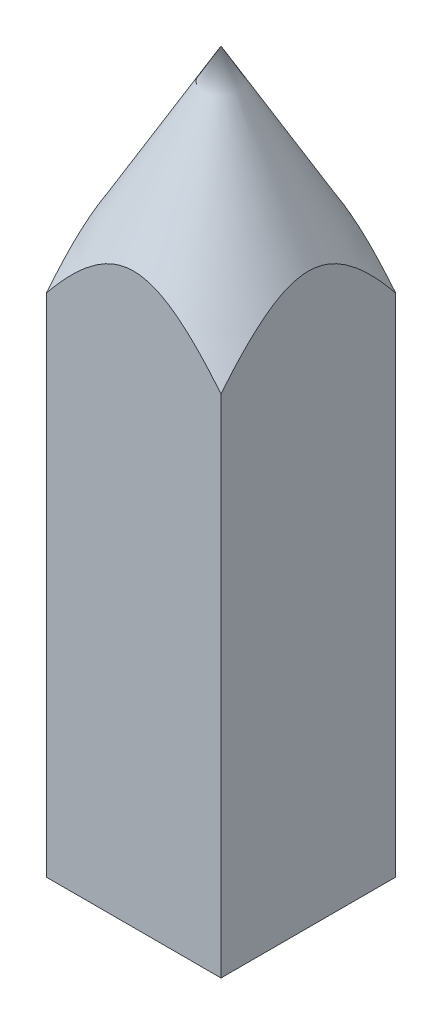
from build123d import *

# Parameters (mm, degrees)
SKETCH5_OUTSIDE_W   = 25.302
SKETCH5_OUTSIDE_H   = 25.302
SKETCH5_OUTSIDE_W_2 = 10
SKETCH5_OUTSIDE_H_2 = 10
EXTRUDE2_DEPTH      = 42.2052629


with BuildPart() as part:
    # Sketch4 → Revolve1 (revolve)
    with BuildSketch(Plane.XY, mode=Mode.PRIVATE) as revolve1_sk:
        Polygon((0, 0), (0, 41.2052629), (7.071067812, 28.957814186), (7.071067812, 0), align=None)
    revolve(revolve1_sk.sketch.rotate(Axis((0, 0, 0), (0, 1, 0)), 90), axis=Axis((0, 0, 0), (0, 1, 0)))  # turned: the seam where the file's is

    # Sketch5 outside → Extrude2 (cut, through all)
    with BuildSketch(Plane(origin=(0, 0, 0), x_dir=(1, 0, 0), z_dir=(0, 1, 0))):
        Rectangle(SKETCH5_OUTSIDE_W, SKETCH5_OUTSIDE_H)
        Rectangle(SKETCH5_OUTSIDE_W_2, SKETCH5_OUTSIDE_H_2, mode=Mode.SUBTRACT)
    extrude(amount=EXTRUDE2_DEPTH, mode=Mode.SUBTRACT)


solid = part.part
